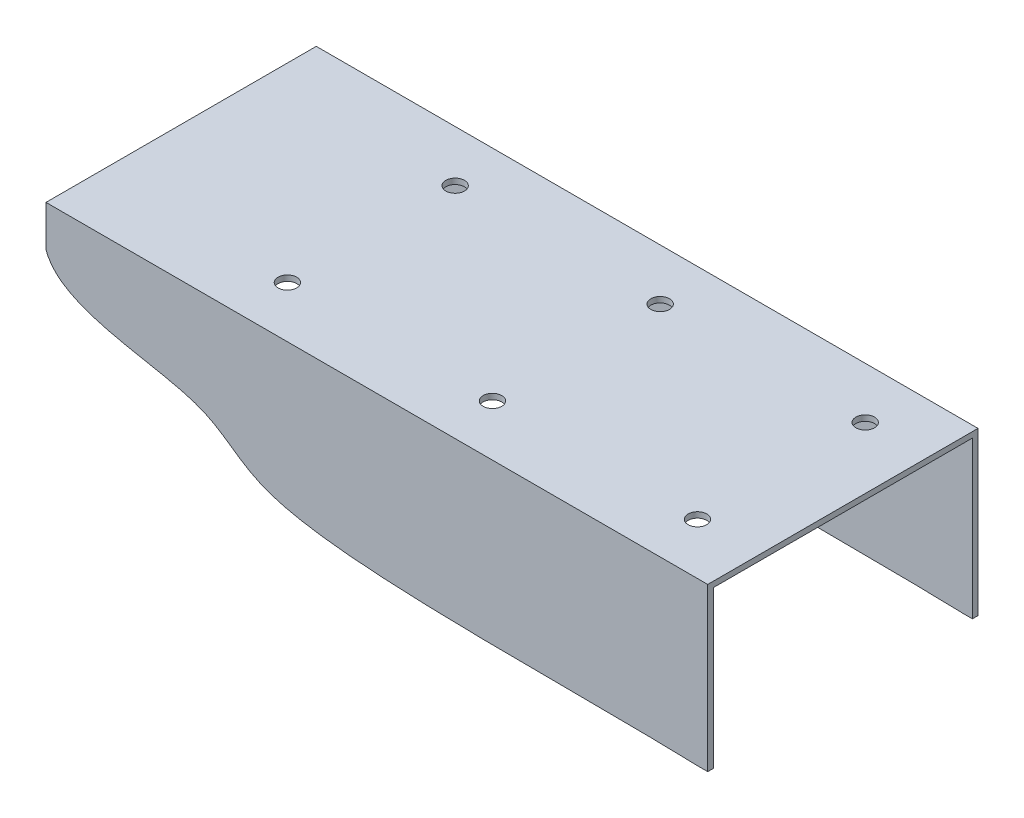
from build123d import *

# Parameters (mm, degrees)
EXTRUDE_1_DEPTH     = 355
CUT_EXTRUDE_1_DEPTH = 146
SKETCH_3_R          = 5
CUT_EXTRUDE_2_DEPTH = 10


with BuildPart() as part:
    # Эскиз1 → Вытянуть-Тонкостенный1 (new body)
    with BuildSketch(Plane(origin=(0, 0, 0), x_dir=(0, 0, -1), z_dir=(1, 0, 0))):
        Polygon((0, 0), (0, 87), (145, 87), (145, 0), (142, 0), (142, 84), (3, 84), (3, 0), align=None)
    extrude(amount=EXTRUDE_1_DEPTH)

    # Эскиз2 → Вырез-Вытянуть1 (cut, through all)
    with BuildSketch(Plane.XY):
        with BuildLine():
            Line((0, 65.12405332), (0, 0))
            Line((0, 0), (350.278484056, 0))
            add(Edge.make_bspline(
                [(0, 65.12405332), (7.933841156, 41.786887325), (88.835587811, 42.671964813), (115.548592719, -4.570720396), (275.808566843, 2.451761606), (350.278484056, 0)],
                knots=[0, 0, 0, 0, 0.332901295, 0.537301133, 1, 1, 1, 1], degree=3))
        make_face()
    extrude(amount=-CUT_EXTRUDE_1_DEPTH, mode=Mode.SUBTRACT)

    # Эскиз3 → Вырез-Вытянуть2 (cut)
    with BuildSketch(Plane(origin=(0, 87, 0), x_dir=(1, 0, 0), z_dir=(0, 1, 0))):
        with Locations((322, 117.5)):
            Circle(SKETCH_3_R)
        with Locations((212, 117.5)):
            Circle(SKETCH_3_R)
        with Locations((102, 117.5)):
            Circle(SKETCH_3_R)
        with Locations((212, 27.5)):
            Circle(SKETCH_3_R)
        with Locations((102, 27.5)):
            Circle(SKETCH_3_R)
        with Locations((322, 27.5)):
            Circle(SKETCH_3_R)
    extrude(amount=-CUT_EXTRUDE_2_DEPTH, mode=Mode.SUBTRACT)


solid = part.part
